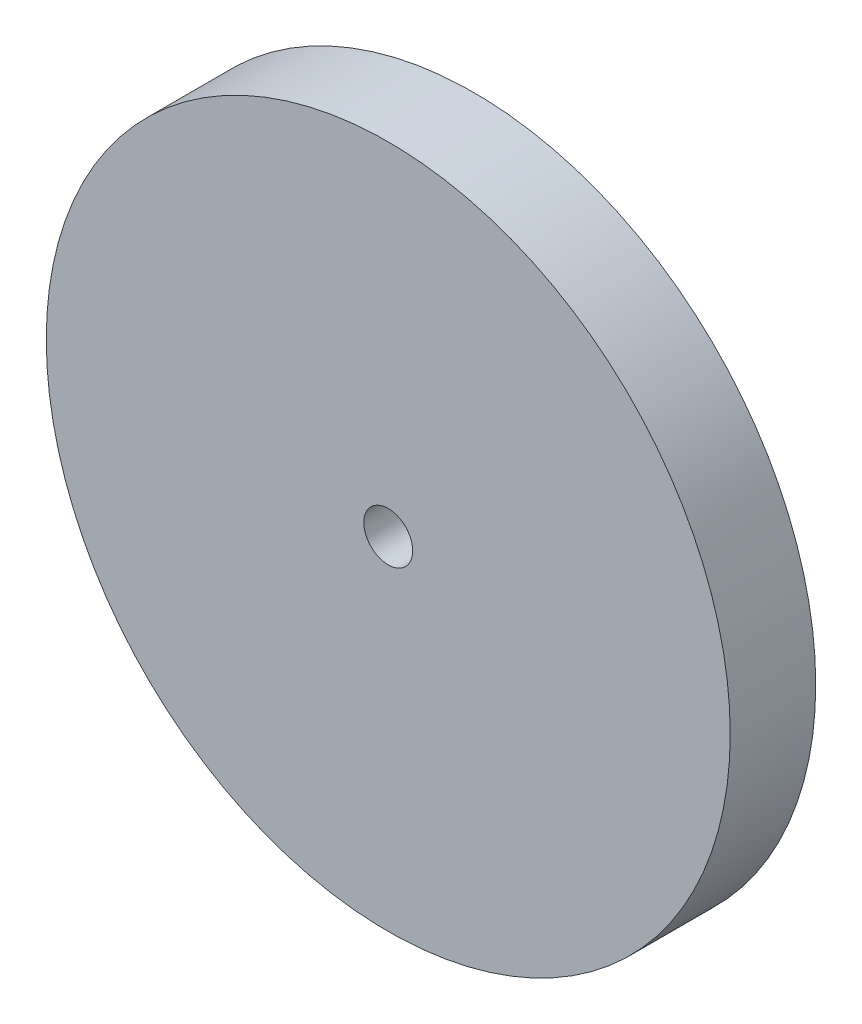
from build123d import *

# Parameters (mm, degrees)
SKETCH1_R           = 14
SKETCH1_R_2         = 1
BOSS_EXTRUDE1_DEPTH = 3.5


with BuildPart() as part:
    # Sketch1 → Boss-Extrude1 (new body)
    with BuildSketch(Plane.XY):
        Circle(SKETCH1_R)
        Circle(SKETCH1_R_2, mode=Mode.SUBTRACT)
    extrude(amount=BOSS_EXTRUDE1_DEPTH)


solid = part.part
